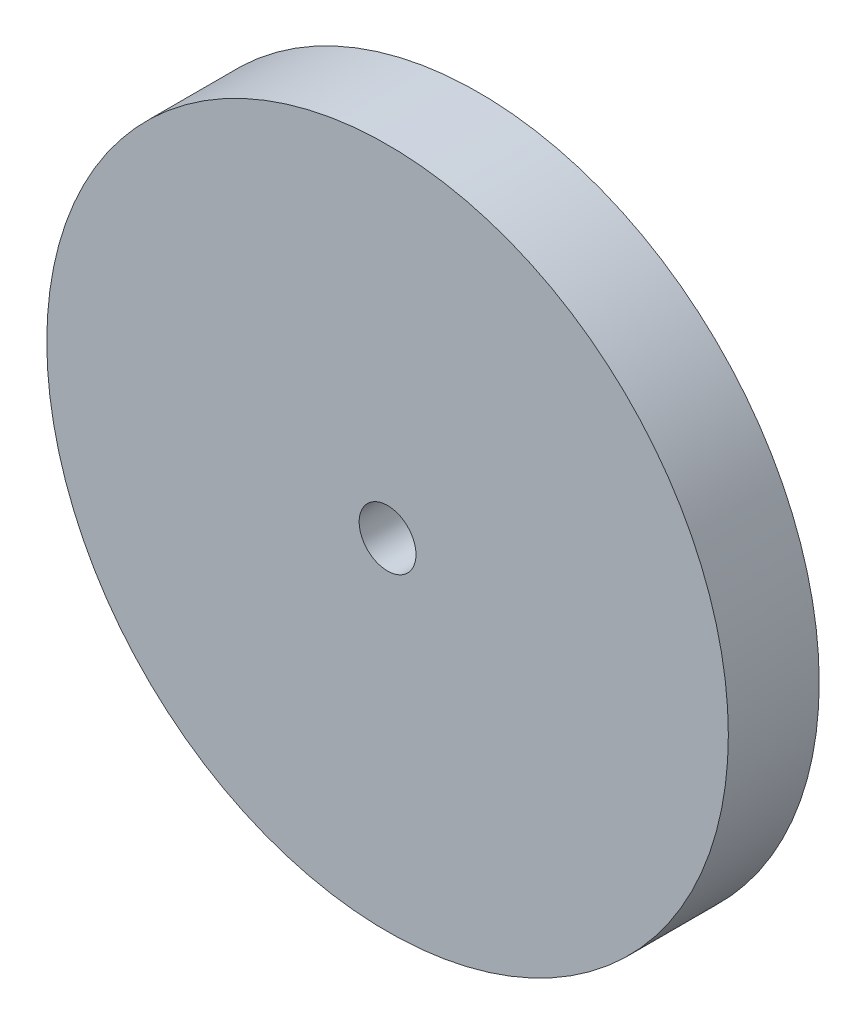
from build123d import *

# Parameters (mm, degrees)
CROQUIS1_R              = 15
CROQUIS1_R_2            = 1.25
SALIENTE_EXTRUIR1_DEPTH = 2


with BuildPart() as part:
    # Croquis1 → Saliente-Extruir1 (new body, symmetric)
    with BuildSketch(Plane.XY):
        Circle(CROQUIS1_R)
        Circle(CROQUIS1_R_2, mode=Mode.SUBTRACT)
    extrude(amount=SALIENTE_EXTRUIR1_DEPTH, both=True)


solid = part.part
